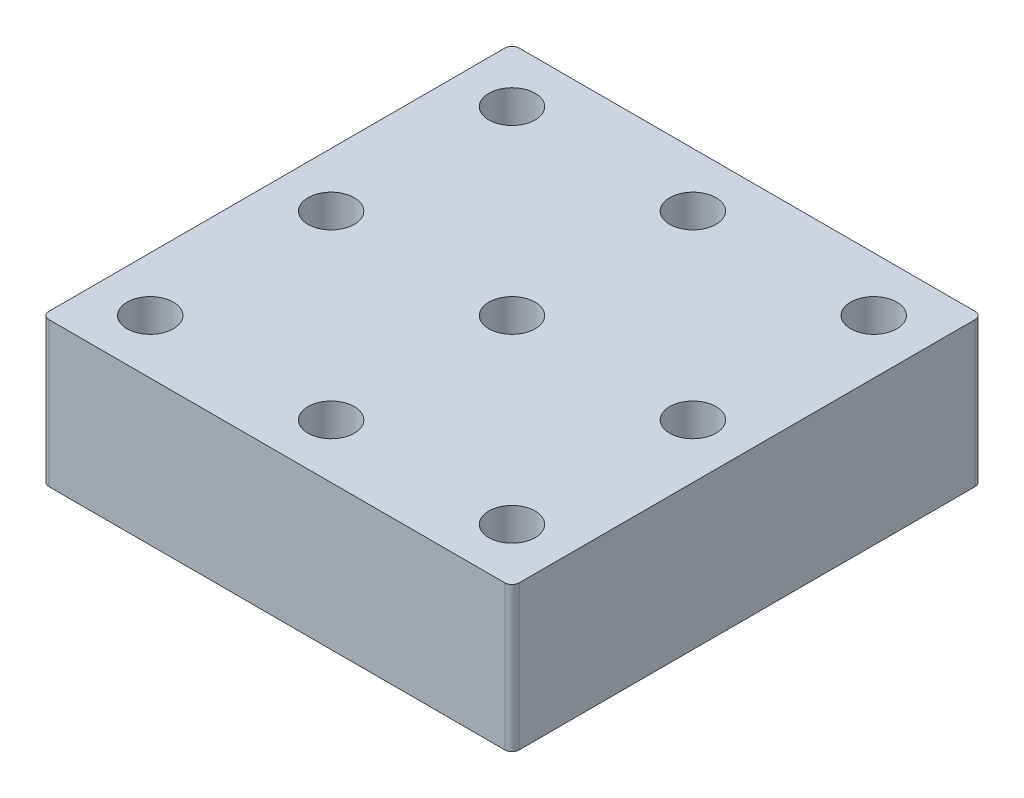
from build123d import *

# Parameters (mm, degrees)
SKETCH_1_W          = 65
SKETCH_1_H          = 65
EXTRUDE_1_DEPTH     = 20
SKETCH_2_R          = 3
CUT_EXTRUDE_1_DEPTH = 7.5
SKETCH_3_R          = 3.2
CUT_EXTRUDE_2_DEPTH = 7.5
FILLET_1_R          = 1


with BuildPart() as part:
    # 스케치1 → 보스-돌출1 (new body)
    with BuildSketch(Plane(origin=(0, 0, 0), x_dir=(1, 0, 0), z_dir=(0, 1, 0))):
        Rectangle(SKETCH_1_W, SKETCH_1_H)
    extrude(amount=EXTRUDE_1_DEPTH)

    # 스케치2 → 컷-돌출1 (cut)
    with BuildSketch(Plane.XZ):
        with Locations((-25, 25)):
            Circle(SKETCH_2_R)
        with Locations((25, 25)):
            Circle(SKETCH_2_R)
        with Locations((25, -25)):
            Circle(SKETCH_2_R)
        with Locations((-25, -25)):
            Circle(SKETCH_2_R)
    extrude(amount=-CUT_EXTRUDE_1_DEPTH, mode=Mode.SUBTRACT)

    # 스케치3 → 컷-돌출2 (cut)
    with BuildSketch(Plane(origin=(0, 20, 0), x_dir=(1, 0, 0), z_dir=(0, 1, 0))):
        with Locations((-25, 25)):
            Circle(SKETCH_3_R)
        with Locations((0, 25)):
            Circle(SKETCH_3_R)
        with Locations((25, 25)):
            Circle(SKETCH_3_R)
        with Locations((25, 0)):
            Circle(SKETCH_3_R)
        with Locations((25, -25)):
            Circle(SKETCH_3_R)
        with Locations((0, -25)):
            Circle(SKETCH_3_R)
        with Locations((-25, -25)):
            Circle(SKETCH_3_R)
        with Locations((-25, 0)):
            Circle(SKETCH_3_R)
        Circle(SKETCH_3_R)
    extrude(amount=-CUT_EXTRUDE_2_DEPTH, mode=Mode.SUBTRACT)

    # 필렛1
    fillet_1_edges = [part.edges().sort_by_distance(p)[0] for p in [
        (-32.5, 10, -32.5),
        (32.5, 10, -32.5),
        (32.5, 10, 32.5),
        (-32.5, 10, 32.5),
    ]]
    fillet(fillet_1_edges, radius=FILLET_1_R)


solid = part.part
